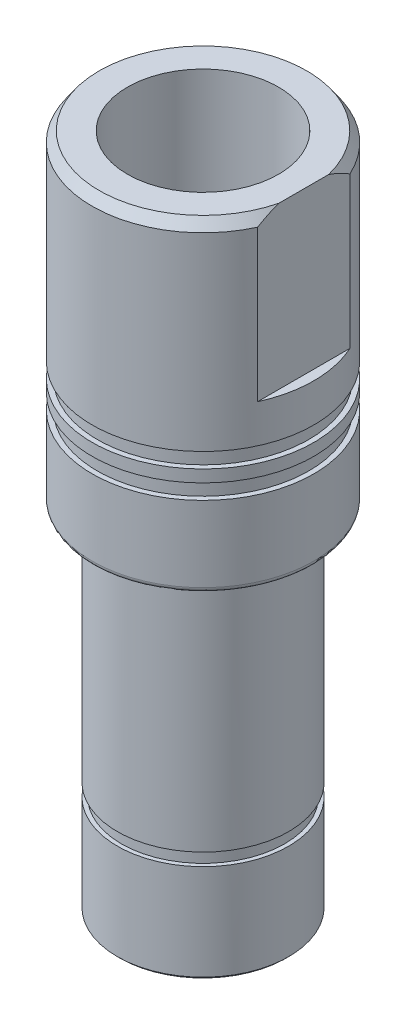
from build123d import *

# Parameters (mm, degrees)
SKETCH3_R           = 8.5
SKETCH3_R_2         = 7
BOSS_EXTRUDE1_DEPTH = 35
SKETCH4_R           = 11
SKETCH4_R_2         = 7
BOSS_EXTRUDE2_DEPTH = 32
SKETCH9_W           = 0.5
SKETCH9_H           = 1.5
SKETCH11_W          = 2
SKETCH11_H          = 10
CUT_EXTRUDE1_DEPTH  = 16
CHAMFER2_SIZE       = 1
CHAMFER2_SIZE2      = 0.700207538
FILLET1_R           = 0.5
CHAMFER3_SIZE       = 0.25
SKETCH14_R          = 7.5
CUT_EXTRUDE3_DEPTH  = 12
BOSS_EXTRUDE3_START = -2
SKETCH12_R          = 7
SKETCH12_R_2        = 4.5
BOSS_EXTRUDE3_DEPTH = 3
BOSS_EXTRUDE4_START = -5
SKETCH12_2_R        = 7
SKETCH12_2_R_2      = 4.5
BOSS_EXTRUDE4_DEPTH = 11
CUT_EXTRUDE2_DEPTH  = 68
CUT_EXTRUDE4_START  = -11
SKETCH15_R          = 8.75
SKETCH15_R_2        = 8.1
CUT_EXTRUDE4_DEPTH  = 1.25


with BuildPart() as part:
    # Sketch3 → Boss-Extrude1 (new body)
    with BuildSketch(Plane(origin=(0, 0, 0), x_dir=(1, 0, 0), z_dir=(0, 1, 0))):
        Circle(SKETCH3_R)
        Circle(SKETCH3_R_2, mode=Mode.SUBTRACT)
    extrude(amount=BOSS_EXTRUDE1_DEPTH)

    # Sketch4 → Boss-Extrude2 (add)
    with BuildSketch(Plane(origin=(0, 35, 0), x_dir=(1, 0, 0), z_dir=(0, 1, 0))):
        Circle(SKETCH4_R)
        Circle(SKETCH4_R_2, mode=Mode.SUBTRACT)
    extrude(amount=BOSS_EXTRUDE2_DEPTH)

    # Cut-Sweep1: sweep along a path in Sketch6
    with BuildLine(Plane(origin=(0, 43, 0), x_dir=(1, 0, 0), z_dir=(0, 1, 0))) as cut_sweep1_path:
        CenterArc((0, 0), 11, 0, 360)
    # Sketch9 → Cut-Sweep1 (sweep, cut)
    with BuildSketch(Plane(origin=(0, 0, 0), x_dir=(0, 0, -1), z_dir=(1, 0, 0))):
        with Locations((10.75, 43.75)):
            Rectangle(SKETCH9_W, SKETCH9_H)
        with Locations((10.75, 46.45)):
            Rectangle(SKETCH9_W, SKETCH9_H)
    sweep(path=cut_sweep1_path.line, mode=Mode.SUBTRACT)

    # Sketch11 → Cut-Extrude1 (cut)
    with BuildSketch(Plane(origin=(0, 67, 0), x_dir=(1, 0, 0), z_dir=(0, 1, 0))):
        with Locations((11, 0)):
            Rectangle(SKETCH11_W, SKETCH11_H)
    extrude(amount=-CUT_EXTRUDE1_DEPTH, mode=Mode.SUBTRACT)

    # Chamfer2
    chamfer2_edges = [part.edges().sort_by_distance(p)[0] for p in [
        (-11, 67, 0),
    ]]
    chamfer2_side = [part.faces().sort_by_distance(p)[0] for p in [
        (-11, 57.1, 0),
    ]]
    chamfer(chamfer2_edges, length=CHAMFER2_SIZE, length2=CHAMFER2_SIZE2, reference=chamfer2_side[0])

    # Fillet1
    fillet1_edges = [part.edges().sort_by_distance(p)[0] for p in [
        (-11, 35, 0),
    ]]
    fillet(fillet1_edges, radius=FILLET1_R)

    # Chamfer3
    chamfer3_edges = [part.edges().sort_by_distance(p)[0] for p in [
        (-8.5, 0, 0),
    ]]
    chamfer(chamfer3_edges, length=CHAMFER3_SIZE)

    # Sketch14 → Cut-Extrude3 (cut)
    with BuildSketch(Plane(origin=(0, 67, 0), x_dir=(1, 0, 0), z_dir=(0, 1, 0))):
        Circle(SKETCH14_R)
    extrude(amount=-CUT_EXTRUDE3_DEPTH, mode=Mode.SUBTRACT)


with BuildPart() as body_2:
    # Sketch12 → Boss-Extrude3 (new body)
    with BuildSketch(Plane(origin=(0, 0, 0), x_dir=(-1, 0, 0), z_dir=(0, -1, 0)).offset(BOSS_EXTRUDE3_START)):
        Circle(SKETCH12_R)
        Circle(SKETCH12_R_2, mode=Mode.SUBTRACT)
    extrude(amount=-BOSS_EXTRUDE3_DEPTH)


with BuildPart() as body_3:
    # Sketch12_2 → Boss-Extrude4 (new body)
    with BuildSketch(Plane(origin=(0, 0, 0), x_dir=(-1, 0, 0), z_dir=(0, -1, 0)).offset(BOSS_EXTRUDE4_START)):
        Circle(SKETCH12_2_R)
        Circle(SKETCH12_2_R_2, mode=Mode.SUBTRACT)
    extrude(amount=-BOSS_EXTRUDE4_DEPTH)

    # Combine1: union part
    add(part.part)


with BuildPart() as cut_extrude2_tool:
    # Sketch13 → Cut-Extrude2 (new body, through all)
    with BuildSketch(Plane.XZ):
        with BuildLine():
            Line((-4.242640687, 1.5), (-5.809475019, 1.5))
            ThreePointArc((-5.809475019, 1.5), (-6, 0), (-5.809475019, -1.5))
            Line((-5.809475019, -1.5), (-4.242640687, -1.5))
            ThreePointArc((-4.242640687, -1.5), (-4.5, 0), (-4.242640687, 1.5))
        make_face()
        with BuildLine():
            Line((1.5, 4.242640687), (1.5, 5.809475019))
            ThreePointArc((1.5, 5.809475019), (0, 6), (-1.5, 5.809475019))
            Line((-1.5, 5.809475019), (-1.5, 4.242640687))
            ThreePointArc((-1.5, 4.242640687), (0, 4.5), (1.5, 4.242640687))
        make_face()
        with BuildLine():
            ThreePointArc((6, 0), (5.952178178, 0.756025755), (5.809475019, 1.5))
            Line((5.809475019, 1.5), (4.242640687, 1.5))
            ThreePointArc((4.242640687, 1.5), (4.435193518, 0.760958904), (4.5, 0))
            ThreePointArc((4.5, 0), (4.435193518, -0.760958904), (4.242640687, -1.5))
            Line((4.242640687, -1.5), (5.809475019, -1.5))
            ThreePointArc((5.809475019, -1.5), (5.952178178, -0.756025755), (6, 0))
        make_face()
        with BuildLine():
            ThreePointArc((-1.5, -5.809475019), (0, -6), (1.5, -5.809475019))
            Line((1.5, -5.809475019), (1.5, -4.242640687))
            ThreePointArc((1.5, -4.242640687), (0, -4.5), (-1.5, -4.242640687))
            Line((-1.5, -4.242640687), (-1.5, -5.809475019))
        make_face()
    extrude(amount=-CUT_EXTRUDE2_DEPTH)


with BuildPart() as body_2_1:
    add(body_2.part)

    # Cut-Extrude2: cut by cut_extrude2_tool
    add(cut_extrude2_tool.part, mode=Mode.SUBTRACT)


with BuildPart() as body_3_1:
    add(body_3.part)

    # Cut-Extrude2: cut by cut_extrude2_tool
    add(cut_extrude2_tool.part, mode=Mode.SUBTRACT)

    # Sketch15 → Cut-Extrude4 (cut)
    with BuildSketch(Plane.XZ.offset(CUT_EXTRUDE4_START)):
        Circle(SKETCH15_R)
        Circle(SKETCH15_R_2, mode=Mode.SUBTRACT)
    extrude(amount=CUT_EXTRUDE4_DEPTH, mode=Mode.SUBTRACT)


solid = Compound([body_2_1.part, body_3_1.part])
